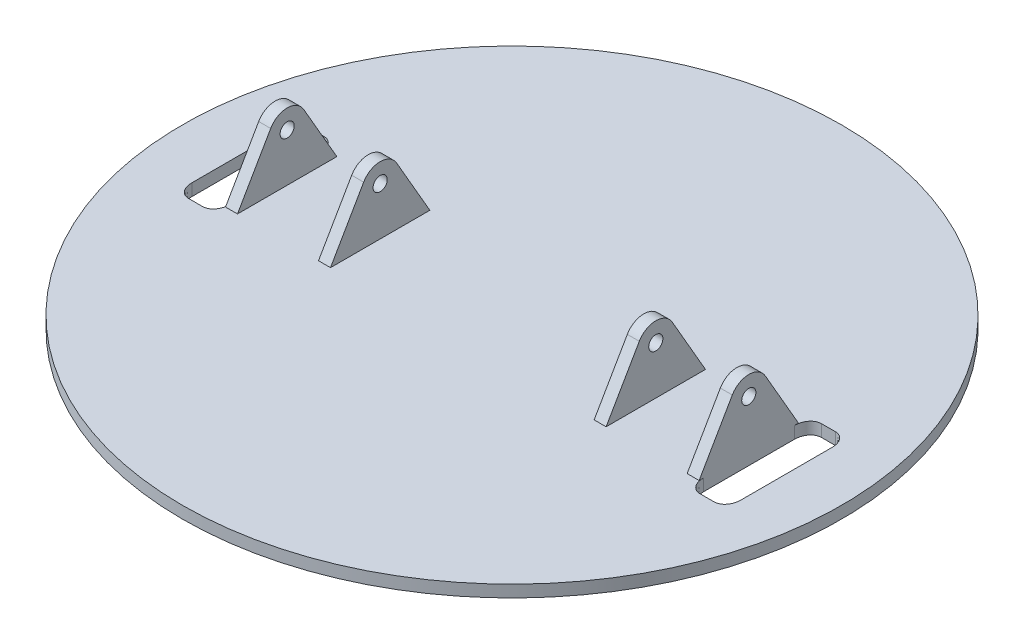
from build123d import *

# Parameters (mm, degrees)
SKETCH1_R           = 69.85
BOSS_EXTRUDE1_DEPTH = 2.54
CUT_EXTRUDE1_DEPTH  = 99.815467413
BOSS_EXTRUDE2_START = 50.192
SKETCH6_R           = 1.500000048
BOSS_EXTRUDE2_DEPTH = 2.54
BOSS_EXTRUDE3_START = -50.192
SKETCH6_2_R         = 1.500000048
BOSS_EXTRUDE3_DEPTH = 2.54
BOSS_EXTRUDE4_START = 27.94
SKETCH6_3_R         = 1.500000048
BOSS_EXTRUDE4_DEPTH = 2.54
BOSS_EXTRUDE5_START = -27.94
SKETCH6_4_R         = 1.500000048
BOSS_EXTRUDE5_DEPTH = 2.54
REVOLVE1_ANGLE      = 180


with BuildPart() as part:
    # Sketch1 → Boss-Extrude1 (new body)
    with BuildSketch(Plane(origin=(0, 0, 0), x_dir=(1, 0, 0), z_dir=(0, 1, 0))):
        with Locations(Location((0, 0, 0), (0, 0, 270))):
            Circle(SKETCH1_R)
    extrude(amount=BOSS_EXTRUDE1_DEPTH)

    # Sketch4 → Cut-Extrude1 (cut, through all)
    with BuildSketch(Plane(origin=(0, 2.54, 0), x_dir=(1, 0, 0), z_dir=(0, 1, 0))):
        with BuildLine():
            Line((-58.208, 9.631888514), (-58.208, -9.631889268))
            add(Edge.make_bspline(
                [(-58.208, -9.631889268), (-58.208015921, -9.985218669), (-58.130777039, -10.689164032), (-57.724991191, -11.716597084), (-56.935897281, -12.599237222), (-56.103541266, -12.868222794), (-55.699980698, -12.868194168)],
                knots=[4.55e-06, 4.55e-06, 4.55e-06, 4.55e-06, 0.250002711, 0.500000873, 0.749999035, 0.999997196, 0.999997196, 0.999997196, 0.999997196], degree=3))
            Line((-55.699980698, -12.868194168), (-52.700019302, -12.868194168))
            add(Edge.make_bspline(
                [(-52.700019302, -12.868194168), (-52.296178776, -12.868222814), (-51.462932581, -12.598414151), (-50.675084586, -11.716743735), (-50.268205425, -10.686485196), (-50.191984113, -9.984638082), (-50.192, -9.631888514)],
                knots=[2.799e-06, 2.799e-06, 2.799e-06, 2.799e-06, 0.250000965, 0.49999913, 0.749997296, 0.999995461, 0.999995461, 0.999995461, 0.999995461], degree=3))
            Line((-50.192, -9.631888514), (-50.192, 9.631889268))
            add(Edge.make_bspline(
                [(-50.192, 9.631889268), (-50.191984079, 9.985218669), (-50.269222961, 10.689164032), (-50.675008809, 11.716597084), (-51.464102719, 12.599237222), (-52.296458734, 12.868222794), (-52.700019302, 12.868194168)],
                knots=[4.55e-06, 4.55e-06, 4.55e-06, 4.55e-06, 0.250002711, 0.500000873, 0.749999035, 0.999997196, 0.999997196, 0.999997196, 0.999997196], degree=3))
            Line((-52.700019302, 12.868194168), (-55.699980698, 12.868194168))
            add(Edge.make_bspline(
                [(-55.699980698, 12.868194168), (-56.103821224, 12.868222814), (-56.93706742, 12.598414151), (-57.724915414, 11.716743734), (-58.131794575, 10.686485196), (-58.208015887, 9.984638082), (-58.208, 9.631888514)],
                knots=[2.799e-06, 2.799e-06, 2.799e-06, 2.799e-06, 0.250000965, 0.49999913, 0.749997296, 0.999995461, 0.999995461, 0.999995461, 0.999995461], degree=3))
        make_face()
        with BuildLine():
            Line((-50.7, -9.631900278), (-50.7, 9.631901038))
            add(Edge.make_bspline(
                [(-52.7, 12.360194168), (-52.660543045, 12.360197394), (-52.581526732, 12.357176393), (-52.458990478, 12.342810716), (-52.339578451, 12.319437383), (-52.22147864, 12.286559843), (-52.105122747, 12.244501481), (-51.990937987, 12.193317687), (-51.879333503, 12.133154033), (-51.673421613, 12.002425371), (-51.392572455, 11.75190052), (-51.108542724, 11.351640508), (-50.898924682, 10.89638005), (-50.777070273, 10.457449832), (-50.714131373, 10.042766184), (-50.69999314, 9.775744558), (-50.7, 9.631901038)],
                knots=[0, 0, 0, 0, 0.032186408, 0.064453943, 0.096880469, 0.129541877, 0.162511195, 0.195857823, 0.229646891, 0.26393876, 0.391040825, 0.527783634, 0.654106325, 0.790546325, 0.891198015, 1, 1, 1, 1], degree=3))
            Line((-52.7, 12.360194168), (-55.7, 12.360194168))
            add(Edge.make_bspline(
                [(-57.7, 9.631900278), (-57.700003497, 9.705266421), (-57.696255035, 9.846713018), (-57.681641642, 10.036669894), (-57.657827677, 10.227708374), (-57.60619141, 10.519368132), (-57.500928131, 10.896361802), (-57.291751816, 11.351113376), (-57.008289301, 11.750754133), (-56.696651354, 12.029288898), (-56.414518772, 12.195927864), (-56.18237574, 12.289823438), (-55.938924091, 12.347916661), (-55.779374994, 12.360200658), (-55.7, 12.360194168)],
                knots=[0, 0, 0, 0, 0.055429119, 0.108848879, 0.16022806, 0.209539049, 0.345987225, 0.472317996, 0.608681282, 0.735454202, 0.803707179, 0.870178354, 0.935409387, 1, 1, 1, 1], degree=3))
            Line((-57.7, 9.631900278), (-57.7, -9.631901038))
            add(Edge.make_bspline(
                [(-55.7, -12.360194168), (-55.739456955, -12.360197394), (-55.818473268, -12.357176393), (-55.941009522, -12.342810716), (-56.060421549, -12.319437383), (-56.17852136, -12.286559843), (-56.294877253, -12.244501481), (-56.409062013, -12.193317687), (-56.520666497, -12.133154033), (-56.726578387, -12.002425371), (-57.007427545, -11.75190052), (-57.291457276, -11.351640508), (-57.501075318, -10.89638005), (-57.622929727, -10.457449832), (-57.685868627, -10.042766184), (-57.70000686, -9.775744558), (-57.7, -9.631901038)],
                knots=[0, 0, 0, 0, 0.032186408, 0.064453943, 0.096880469, 0.129541877, 0.162511195, 0.195857823, 0.229646891, 0.26393876, 0.391040825, 0.527783634, 0.654106325, 0.790546325, 0.891198015, 1, 1, 1, 1], degree=3))
            Line((-55.7, -12.360194168), (-52.7, -12.360194168))
            add(Edge.make_bspline(
                [(-50.7, -9.631900278), (-50.699996503, -9.705266421), (-50.703744965, -9.846713018), (-50.718358358, -10.036669894), (-50.742172323, -10.227708374), (-50.79380859, -10.519368132), (-50.899071869, -10.896361802), (-51.108248184, -11.351113376), (-51.391710699, -11.750754133), (-51.703348646, -12.029288898), (-51.985481228, -12.195927864), (-52.21762426, -12.289823438), (-52.461075909, -12.347916661), (-52.620625006, -12.360200658), (-52.7, -12.360194168)],
                knots=[0, 0, 0, 0, 0.055429119, 0.108848879, 0.16022806, 0.209539049, 0.345987225, 0.472317996, 0.608681282, 0.735454202, 0.803707179, 0.870178354, 0.935409387, 1, 1, 1, 1], degree=3))
        make_face(mode=Mode.SUBTRACT)
        with BuildLine():
            add(Edge.make_bspline(
                [(-50.7, -9.631900278), (-50.699996503, -9.705266421), (-50.703744965, -9.846713018), (-50.718358358, -10.036669894), (-50.742172323, -10.227708374), (-50.79380859, -10.519368132), (-50.899071869, -10.896361802), (-51.108248184, -11.351113376), (-51.391710699, -11.750754133), (-51.703348646, -12.029288898), (-51.985481228, -12.195927864), (-52.21762426, -12.289823438), (-52.461075909, -12.347916661), (-52.620625006, -12.360200658), (-52.7, -12.360194168)],
                knots=[0, 0, 0, 0, 0.055429119, 0.108848879, 0.16022806, 0.209539049, 0.345987225, 0.472317996, 0.608681282, 0.735454202, 0.803707179, 0.870178354, 0.935409387, 1, 1, 1, 1], degree=3))
            Line((-52.7, -12.360194168), (-55.7, -12.360194168))
            add(Edge.make_bspline(
                [(-55.7, -12.360194168), (-55.739456955, -12.360197394), (-55.818473268, -12.357176393), (-55.941009522, -12.342810716), (-56.060421549, -12.319437383), (-56.17852136, -12.286559843), (-56.294877253, -12.244501481), (-56.409062013, -12.193317687), (-56.520666497, -12.133154033), (-56.726578387, -12.002425371), (-57.007427545, -11.75190052), (-57.291457276, -11.351640508), (-57.501075318, -10.89638005), (-57.622929727, -10.457449832), (-57.685868627, -10.042766184), (-57.70000686, -9.775744558), (-57.7, -9.631901038)],
                knots=[0, 0, 0, 0, 0.032186408, 0.064453943, 0.096880469, 0.129541877, 0.162511195, 0.195857823, 0.229646891, 0.26393876, 0.391040825, 0.527783634, 0.654106325, 0.790546325, 0.891198015, 1, 1, 1, 1], degree=3))
            Line((-57.7, -9.631901038), (-57.7, 9.631900278))
            add(Edge.make_bspline(
                [(-57.7, 9.631900278), (-57.700003497, 9.705266421), (-57.696255035, 9.846713018), (-57.681641642, 10.036669894), (-57.657827677, 10.227708374), (-57.60619141, 10.519368132), (-57.500928131, 10.896361802), (-57.291751816, 11.351113376), (-57.008289301, 11.750754133), (-56.696651354, 12.029288898), (-56.414518772, 12.195927864), (-56.18237574, 12.289823438), (-55.938924091, 12.347916661), (-55.779374994, 12.360200658), (-55.7, 12.360194168)],
                knots=[0, 0, 0, 0, 0.055429119, 0.108848879, 0.16022806, 0.209539049, 0.345987225, 0.472317996, 0.608681282, 0.735454202, 0.803707179, 0.870178354, 0.935409387, 1, 1, 1, 1], degree=3))
            Line((-55.7, 12.360194168), (-52.7, 12.360194168))
            add(Edge.make_bspline(
                [(-52.7, 12.360194168), (-52.660543045, 12.360197394), (-52.581526732, 12.357176393), (-52.458990478, 12.342810716), (-52.339578451, 12.319437383), (-52.22147864, 12.286559843), (-52.105122747, 12.244501481), (-51.990937987, 12.193317687), (-51.879333503, 12.133154033), (-51.673421613, 12.002425371), (-51.392572455, 11.75190052), (-51.108542724, 11.351640508), (-50.898924682, 10.89638005), (-50.777070273, 10.457449832), (-50.714131373, 10.042766184), (-50.69999314, 9.775744558), (-50.7, 9.631901038)],
                knots=[0, 0, 0, 0, 0.032186408, 0.064453943, 0.096880469, 0.129541877, 0.162511195, 0.195857823, 0.229646891, 0.26393876, 0.391040825, 0.527783634, 0.654106325, 0.790546325, 0.891198015, 1, 1, 1, 1], degree=3))
            Line((-50.7, 9.631901038), (-50.7, -9.631900278))
        make_face()
        with BuildLine():
            Line((50.192, 9.631888514), (50.192, -9.631889268))
            add(Edge.make_bspline(
                [(50.192, -9.631889268), (50.191984079, -9.98521867), (50.269222961, -10.689164033), (50.675008809, -11.716597085), (51.464102719, -12.599237222), (52.296458734, -12.868222794), (52.700019302, -12.868194168)],
                knots=[4.55e-06, 4.55e-06, 4.55e-06, 4.55e-06, 0.250002711, 0.500000873, 0.749999035, 0.999997196, 0.999997196, 0.999997196, 0.999997196], degree=3))
            Line((52.700019302, -12.868194168), (55.699980698, -12.868194168))
            add(Edge.make_bspline(
                [(55.699980698, -12.868194168), (56.103821223, -12.868222814), (56.937067419, -12.598414151), (57.724915414, -11.716743735), (58.131794575, -10.686485196), (58.208015887, -9.984638082), (58.208, -9.631888514)],
                knots=[2.799e-06, 2.799e-06, 2.799e-06, 2.799e-06, 0.250000965, 0.49999913, 0.749997296, 0.999995462, 0.999995462, 0.999995462, 0.999995462], degree=3))
            Line((58.208, -9.631888514), (58.208, 9.631889268))
            add(Edge.make_bspline(
                [(58.208, 9.631889268), (58.208015921, 9.985218669), (58.130777039, 10.689164032), (57.724991191, 11.716597084), (56.935897281, 12.599237222), (56.103541266, 12.868222794), (55.699980699, 12.868194168)],
                knots=[4.55e-06, 4.55e-06, 4.55e-06, 4.55e-06, 0.250002711, 0.500000873, 0.749999035, 0.999997196, 0.999997196, 0.999997196, 0.999997196], degree=3))
            Line((55.699980699, 12.868194168), (52.700019302, 12.868194168))
            add(Edge.make_bspline(
                [(52.700019302, 12.868194168), (52.296178776, 12.868222814), (51.46293258, 12.598414151), (50.675084586, 11.716743734), (50.268205425, 10.686485196), (50.191984113, 9.984638082), (50.192, 9.631888514)],
                knots=[2.799e-06, 2.799e-06, 2.799e-06, 2.799e-06, 0.250000965, 0.49999913, 0.749997296, 0.999995461, 0.999995461, 0.999995461, 0.999995461], degree=3))
        make_face()
        with BuildLine():
            Line((57.7, 9.631901038), (57.7, -9.631900278))
            add(Edge.make_bspline(
                [(57.7, -9.631900278), (57.700003497, -9.705266421), (57.696255035, -9.846713018), (57.681641642, -10.036669894), (57.657827677, -10.227708374), (57.60619141, -10.519368132), (57.500928131, -10.896361802), (57.291751816, -11.351113376), (57.008289301, -11.750754133), (56.696651354, -12.029288898), (56.414518772, -12.195927864), (56.18237574, -12.289823438), (55.938924091, -12.347916661), (55.779374994, -12.360200658), (55.7, -12.360194168)],
                knots=[0, 0, 0, 0, 0.055429119, 0.108848879, 0.16022806, 0.209539049, 0.345987225, 0.472317996, 0.608681282, 0.735454202, 0.803707179, 0.870178354, 0.935409387, 1, 1, 1, 1], degree=3))
            Line((55.7, -12.360194168), (52.7, -12.360194168))
            add(Edge.make_bspline(
                [(52.7, -12.360194168), (52.660543045, -12.360197394), (52.581526732, -12.357176393), (52.458990478, -12.342810716), (52.339578451, -12.319437383), (52.22147864, -12.286559843), (52.105122747, -12.244501481), (51.990937987, -12.193317687), (51.879333503, -12.133154033), (51.673421613, -12.002425371), (51.392572455, -11.75190052), (51.108542724, -11.351640508), (50.898924682, -10.89638005), (50.777070273, -10.457449832), (50.714131373, -10.042766184), (50.69999314, -9.775744558), (50.7, -9.631901038)],
                knots=[0, 0, 0, 0, 0.032186408, 0.064453943, 0.096880469, 0.129541877, 0.162511195, 0.195857823, 0.229646891, 0.26393876, 0.391040825, 0.527783634, 0.654106325, 0.790546325, 0.891198015, 1, 1, 1, 1], degree=3))
            Line((50.7, -9.631901038), (50.7, 9.631900278))
            add(Edge.make_bspline(
                [(50.7, 9.631900278), (50.699996503, 9.705266421), (50.703744965, 9.846713018), (50.718358358, 10.036669894), (50.742172323, 10.227708374), (50.79380859, 10.519368132), (50.899071869, 10.896361802), (51.108248184, 11.351113376), (51.391710699, 11.750754133), (51.703348646, 12.029288898), (51.985481228, 12.195927864), (52.21762426, 12.289823438), (52.461075909, 12.347916661), (52.620625006, 12.360200658), (52.7, 12.360194168)],
                knots=[0, 0, 0, 0, 0.055429119, 0.108848879, 0.16022806, 0.209539049, 0.345987225, 0.472317996, 0.608681282, 0.735454202, 0.803707179, 0.870178354, 0.935409387, 1, 1, 1, 1], degree=3))
            Line((52.7, 12.360194168), (55.7, 12.360194168))
            add(Edge.make_bspline(
                [(55.7, 12.360194168), (55.739456955, 12.360197394), (55.818473268, 12.357176393), (55.941009522, 12.342810716), (56.060421549, 12.319437383), (56.17852136, 12.286559843), (56.294877253, 12.244501481), (56.409062013, 12.193317687), (56.520666497, 12.133154033), (56.726578387, 12.002425371), (57.007427545, 11.75190052), (57.291457276, 11.351640508), (57.501075318, 10.89638005), (57.622929727, 10.457449832), (57.685868627, 10.042766184), (57.70000686, 9.775744558), (57.7, 9.631901038)],
                knots=[0, 0, 0, 0, 0.032186408, 0.064453943, 0.096880469, 0.129541877, 0.162511195, 0.195857823, 0.229646891, 0.26393876, 0.391040825, 0.527783634, 0.654106325, 0.790546325, 0.891198015, 1, 1, 1, 1], degree=3))
        make_face(mode=Mode.SUBTRACT)
        with BuildLine():
            add(Edge.make_bspline(
                [(57.7, -9.631900278), (57.700003497, -9.705266421), (57.696255035, -9.846713018), (57.681641642, -10.036669894), (57.657827677, -10.227708374), (57.60619141, -10.519368132), (57.500928131, -10.896361802), (57.291751816, -11.351113376), (57.008289301, -11.750754133), (56.696651354, -12.029288898), (56.414518772, -12.195927864), (56.18237574, -12.289823438), (55.938924091, -12.347916661), (55.779374994, -12.360200658), (55.7, -12.360194168)],
                knots=[0, 0, 0, 0, 0.055429119, 0.108848879, 0.16022806, 0.209539049, 0.345987225, 0.472317996, 0.608681282, 0.735454202, 0.803707179, 0.870178354, 0.935409387, 1, 1, 1, 1], degree=3))
            Line((55.7, -12.360194168), (52.7, -12.360194168))
            add(Edge.make_bspline(
                [(52.7, -12.360194168), (52.660543045, -12.360197394), (52.581526732, -12.357176393), (52.458990478, -12.342810716), (52.339578451, -12.319437383), (52.22147864, -12.286559843), (52.105122747, -12.244501481), (51.990937987, -12.193317687), (51.879333503, -12.133154033), (51.673421613, -12.002425371), (51.392572455, -11.75190052), (51.108542724, -11.351640508), (50.898924682, -10.89638005), (50.777070273, -10.457449832), (50.714131373, -10.042766184), (50.69999314, -9.775744558), (50.7, -9.631901038)],
                knots=[0, 0, 0, 0, 0.032186408, 0.064453943, 0.096880469, 0.129541877, 0.162511195, 0.195857823, 0.229646891, 0.26393876, 0.391040825, 0.527783634, 0.654106325, 0.790546325, 0.891198015, 1, 1, 1, 1], degree=3))
            Line((50.7, -9.631901038), (50.7, 9.631900278))
            add(Edge.make_bspline(
                [(50.7, 9.631900278), (50.699996503, 9.705266421), (50.703744965, 9.846713018), (50.718358358, 10.036669894), (50.742172323, 10.227708374), (50.79380859, 10.519368132), (50.899071869, 10.896361802), (51.108248184, 11.351113376), (51.391710699, 11.750754133), (51.703348646, 12.029288898), (51.985481228, 12.195927864), (52.21762426, 12.289823438), (52.461075909, 12.347916661), (52.620625006, 12.360200658), (52.7, 12.360194168)],
                knots=[0, 0, 0, 0, 0.055429119, 0.108848879, 0.16022806, 0.209539049, 0.345987225, 0.472317996, 0.608681282, 0.735454202, 0.803707179, 0.870178354, 0.935409387, 1, 1, 1, 1], degree=3))
            Line((52.7, 12.360194168), (55.7, 12.360194168))
            add(Edge.make_bspline(
                [(55.7, 12.360194168), (55.739456955, 12.360197394), (55.818473268, 12.357176393), (55.941009522, 12.342810716), (56.060421549, 12.319437383), (56.17852136, 12.286559843), (56.294877253, 12.244501481), (56.409062013, 12.193317687), (56.520666497, 12.133154033), (56.726578387, 12.002425371), (57.007427545, 11.75190052), (57.291457276, 11.351640508), (57.501075318, 10.89638005), (57.622929727, 10.457449832), (57.685868627, 10.042766184), (57.70000686, 9.775744558), (57.7, 9.631901038)],
                knots=[0, 0, 0, 0, 0.032186408, 0.064453943, 0.096880469, 0.129541877, 0.162511195, 0.195857823, 0.229646891, 0.26393876, 0.391040825, 0.527783634, 0.654106325, 0.790546325, 0.891198015, 1, 1, 1, 1], degree=3))
            Line((57.7, 9.631901038), (57.7, -9.631900278))
        make_face()
    extrude(amount=-CUT_EXTRUDE1_DEPTH, mode=Mode.SUBTRACT)

    # Sketch6 → Boss-Extrude2 (add)
    with BuildSketch(Plane(origin=(0, 0, 0), x_dir=(0, 0, -1), z_dir=(1, 0, 0)).offset(BOSS_EXTRUDE2_START)):
        with BuildLine():
            Line((3.498742673, 14.720000024), (10.530868965, 2.54))
            Line((10.530868965, 2.54), (-10.530868965, 2.54))
            Line((-10.530868965, 2.54), (-3.498742673, 14.720000024))
            ThreePointArc((-3.498742673, 14.720000024), (0, 16.740000048), (3.498742673, 14.720000024))
        make_face()
        with Locations(Location((0, 12.7, 0), (0, 0, 180))):
            Circle(SKETCH6_R, mode=Mode.SUBTRACT)
    extrude(amount=-BOSS_EXTRUDE2_DEPTH)

    # Sketch6_2 → Boss-Extrude3 (add)
    with BuildSketch(Plane(origin=(0, 0, 0), x_dir=(0, 0, -1), z_dir=(1, 0, 0)).offset(BOSS_EXTRUDE3_START)):
        with BuildLine():
            Line((3.498742673, 14.720000024), (10.530868965, 2.54))
            Line((10.530868965, 2.54), (-10.530868965, 2.54))
            Line((-10.530868965, 2.54), (-3.498742673, 14.720000024))
            ThreePointArc((-3.498742673, 14.720000024), (0, 16.740000048), (3.498742673, 14.720000024))
        make_face()
        with Locations(Location((0, 12.7, 0), (0, 0, 180))):
            Circle(SKETCH6_2_R, mode=Mode.SUBTRACT)
    extrude(amount=BOSS_EXTRUDE3_DEPTH)

    # Sketch6_3 → Boss-Extrude4 (add)
    with BuildSketch(Plane(origin=(0, 0, 0), x_dir=(0, 0, -1), z_dir=(1, 0, 0)).offset(BOSS_EXTRUDE4_START)):
        with BuildLine():
            Line((3.498742673, 14.720000024), (10.530868965, 2.54))
            Line((10.530868965, 2.54), (-10.530868965, 2.54))
            Line((-10.530868965, 2.54), (-3.498742673, 14.720000024))
            ThreePointArc((-3.498742673, 14.720000024), (0, 16.740000048), (3.498742673, 14.720000024))
        make_face()
        with Locations(Location((0, 12.7, 0), (0, 0, 180))):
            Circle(SKETCH6_3_R, mode=Mode.SUBTRACT)
    extrude(amount=BOSS_EXTRUDE4_DEPTH)

    # Sketch6_4 → Boss-Extrude5 (add)
    with BuildSketch(Plane(origin=(0, 0, 0), x_dir=(0, 0, -1), z_dir=(1, 0, 0)).offset(BOSS_EXTRUDE5_START)):
        with BuildLine():
            Line((3.498742673, 14.720000024), (10.530868965, 2.54))
            Line((10.530868965, 2.54), (-10.530868965, 2.54))
            Line((-10.530868965, 2.54), (-3.498742673, 14.720000024))
            ThreePointArc((-3.498742673, 14.720000024), (0, 16.740000048), (3.498742673, 14.720000024))
        make_face()
        with Locations(Location((0, 12.7, 0), (0, 0, 180))):
            Circle(SKETCH6_4_R, mode=Mode.SUBTRACT)
    extrude(amount=-BOSS_EXTRUDE5_DEPTH)

    # Sketch7 → Revolve1 (revolve)
    with BuildSketch(Plane.XZ):
        with BuildLine():
            Line((0, 45.72), (0, 55.88))
            ThreePointArc((0, 55.88), (5.08, 50.8), (0, 45.72))
        make_face()
    revolve1 = revolve(axis=Axis((0, 0, 45.72), (0, 0, -1)), revolution_arc=REVOLVE1_ANGLE)

    # Mirror1: Revolve1 across plane
    add(revolve1.mirror(Plane.XY))


solid = part.part
